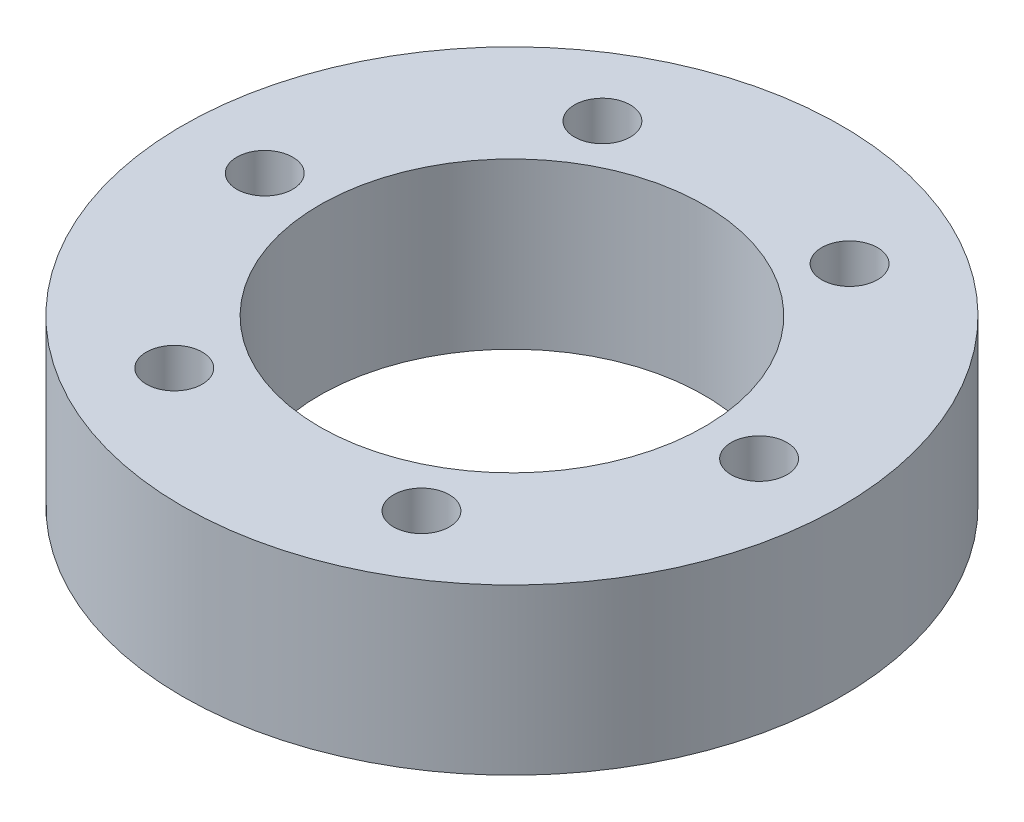
from build123d import *

# Parameters (mm, degrees)
SKETCH_1_R          = 18
EXTRUDE_1_DEPTH     = 9
SKETCH_2_R          = 1.525
CUT_EXTRUDE_1_DEPTH = 10
SKETCH_3_R          = 10.5
CUT_EXTRUDE_2_DEPTH = 10


with BuildPart() as part:
    # 草图1 → 凸台-拉伸1 (new body)
    with BuildSketch(Plane(origin=(0, 0, 0), x_dir=(1, 0, 0), z_dir=(0, 1, 0))):
        Circle(SKETCH_1_R)
    extrude(amount=EXTRUDE_1_DEPTH)

    # 草图2 → 切除-拉伸1 (cut, through all)
    with BuildSketch(Plane(origin=(0, 9, 0), x_dir=(1, 0, 0), z_dir=(0, 1, 0))):
        with Locations((13.5, 0)):
            Circle(SKETCH_2_R)
        with Locations((6.75, -11.691342951)):
            Circle(SKETCH_2_R)
        with Locations((-6.75, -11.691342951)):
            Circle(SKETCH_2_R)
        with Locations((-13.5, 0)):
            Circle(SKETCH_2_R)
        with Locations((-6.75, 11.691342951)):
            Circle(SKETCH_2_R)
        with Locations((6.75, 11.691342951)):
            Circle(SKETCH_2_R)
    extrude(amount=-CUT_EXTRUDE_1_DEPTH, mode=Mode.SUBTRACT)

    # 草图3 → 切除-拉伸2 (cut, through all)
    with BuildSketch(Plane(origin=(0, 9, 0), x_dir=(1, 0, 0), z_dir=(0, 1, 0))):
        Circle(SKETCH_3_R)
    extrude(amount=-CUT_EXTRUDE_2_DEPTH, mode=Mode.SUBTRACT)


solid = part.part
